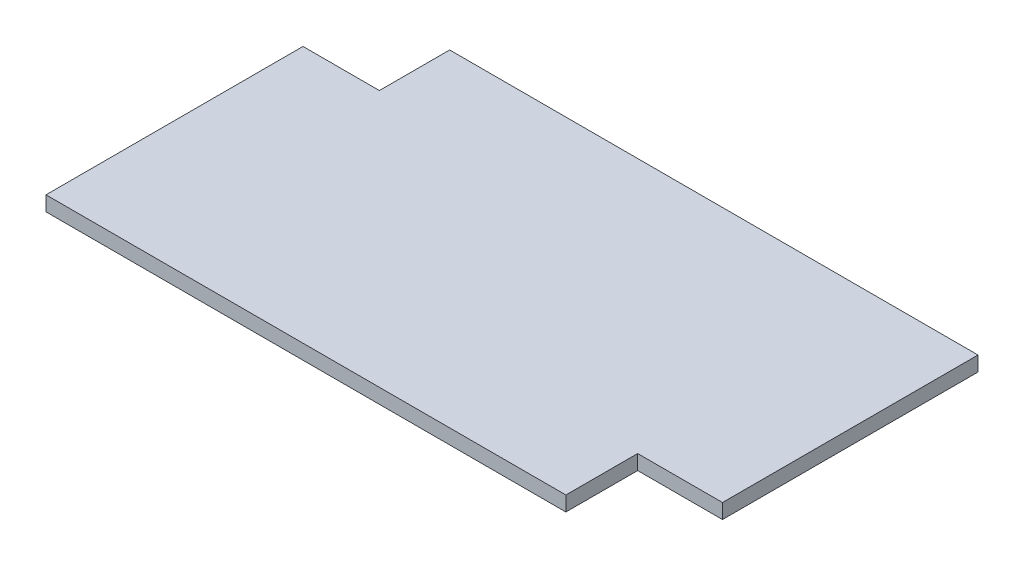
from build123d import *

# Parameters (mm, degrees)
BOSS_EXTRUDE1_DEPTH = 3


with BuildPart() as part:
    # Sketch1 → Boss-Extrude1 (new body)
    with BuildSketch(Plane(origin=(0, 0, 0), x_dir=(1, 0, 0), z_dir=(0, 1, 0))):
        Polygon((45.331216218, -48.900194758), (45.331216218, -34.326324816), (62.557308969, -34.326324816), (62.557308969, 17.551839423), (-44.718611512, 17.551839423), (-44.718611512, 3.28093689), (-60.227321225, 3.28093689), (-60.227321225, -48.900194758), align=None)
    extrude(amount=BOSS_EXTRUDE1_DEPTH)


solid = part.part
